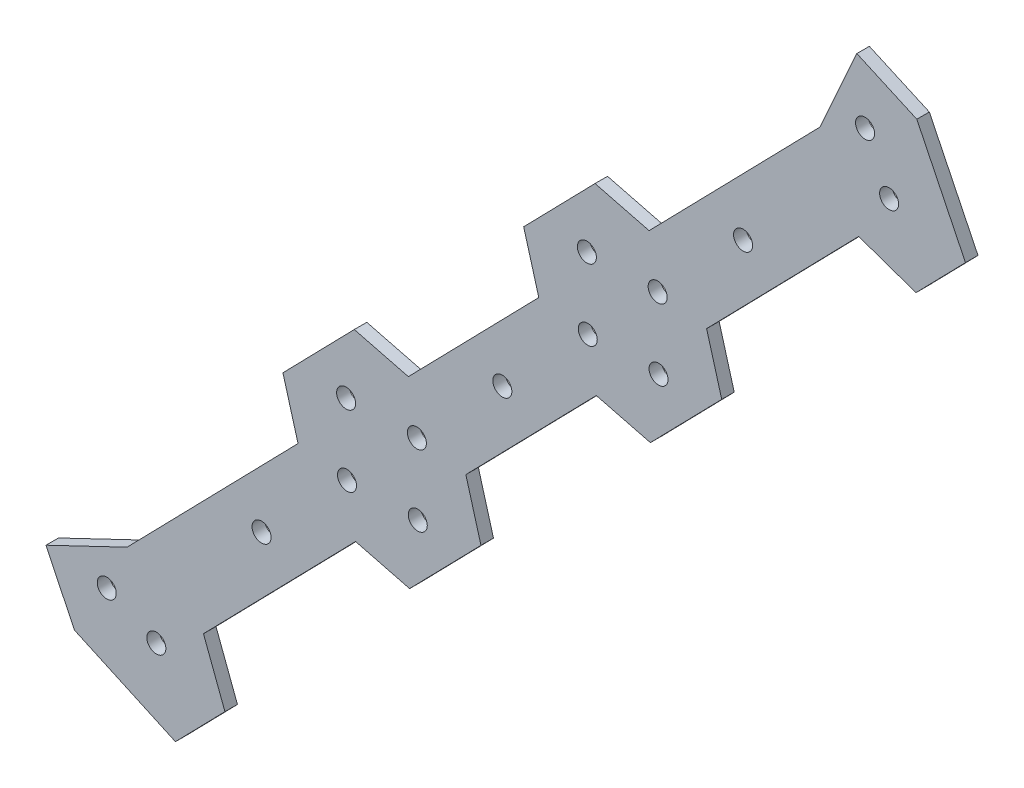
from build123d import *

# Parameters (mm, degrees)
SKETCH_1_R      = 1.52
EXTRUDE_1_DEPTH = 2


with BuildPart() as part:
    # 草图1 → 凸台-拉伸1 (new body)
    with BuildSketch(Plane.XY):
        Polygon((-122.332772904, 193.928670444), (-130.112569709, 209.893801205), (-139.698830821, 214.194588314), (-145.581311392, 201.082803585), (-172.906818534, 173.07089056), (-181.550834018, 175.272509679), (-192.956593094, 163.580242467), (-190.541243439, 154.993495907), (-211.394103482, 133.616820304), (-220.038118966, 135.818439423), (-231.443878041, 124.126172211), (-229.028528386, 115.539425652), (-256.354035527, 87.527512628), (-269.315875894, 81.321614566), (-264.778632454, 71.844980469), (-248.625442054, 64.46357962), (-240.711857184, 72.575950598), (-244.144105033, 81.654022148), (-219.836292658, 106.572437113), (-211.192277174, 104.370817994), (-199.786518099, 116.063085206), (-202.201867754, 124.649831766), (-181.34900771, 146.026507369), (-172.704992227, 143.82488825), (-161.299233151, 155.517155462), (-163.714582806, 164.103902021), (-139.406770431, 189.022316987), (-130.246357773, 185.816299466), align=None)
        with Locations((-259.604526823, 80.250654079)):
            Circle(SKETCH_1_R, mode=Mode.SUBTRACT)
        with Locations((-251.678290532, 76.597666862)):
            Circle(SKETCH_1_R, mode=Mode.SUBTRACT)
        with Locations((-234.858840543, 100.367593581)):
            Circle(SKETCH_1_R, mode=Mode.SUBTRACT)
        with Locations((-221.201454913, 114.368047313)):
            Circle(SKETCH_1_R, mode=Mode.SUBTRACT)
        with Locations((-221.341779466, 125.680885552)):
            Circle(SKETCH_1_R, mode=Mode.SUBTRACT)
        with Locations((-210.028941227, 125.821210105)):
            Circle(SKETCH_1_R, mode=Mode.SUBTRACT)
        with Locations((-196.371555596, 139.821663837)):
            Circle(SKETCH_1_R, mode=Mode.SUBTRACT)
        with Locations((-182.714169966, 153.822117568)):
            Circle(SKETCH_1_R, mode=Mode.SUBTRACT)
        with Locations((-171.401331727, 153.962442121)):
            Circle(SKETCH_1_R, mode=Mode.SUBTRACT)
        with Locations((-182.854494518, 165.134955807)):
            Circle(SKETCH_1_R, mode=Mode.SUBTRACT)
        with Locations((-171.541656279, 165.27528036)):
            Circle(SKETCH_1_R, mode=Mode.SUBTRACT)
        with Locations((-157.884270649, 179.275734092)):
            Circle(SKETCH_1_R, mode=Mode.SUBTRACT)
        with Locations((-134.538850305, 196.679603292)):
            Circle(SKETCH_1_R, mode=Mode.SUBTRACT)
        with Locations((-138.387317573, 204.512791471)):
            Circle(SKETCH_1_R, mode=Mode.SUBTRACT)
        with Locations((-209.888616674, 114.508371866)):
            Circle(SKETCH_1_R, mode=Mode.SUBTRACT)
    extrude(amount=EXTRUDE_1_DEPTH)


solid = part.part
